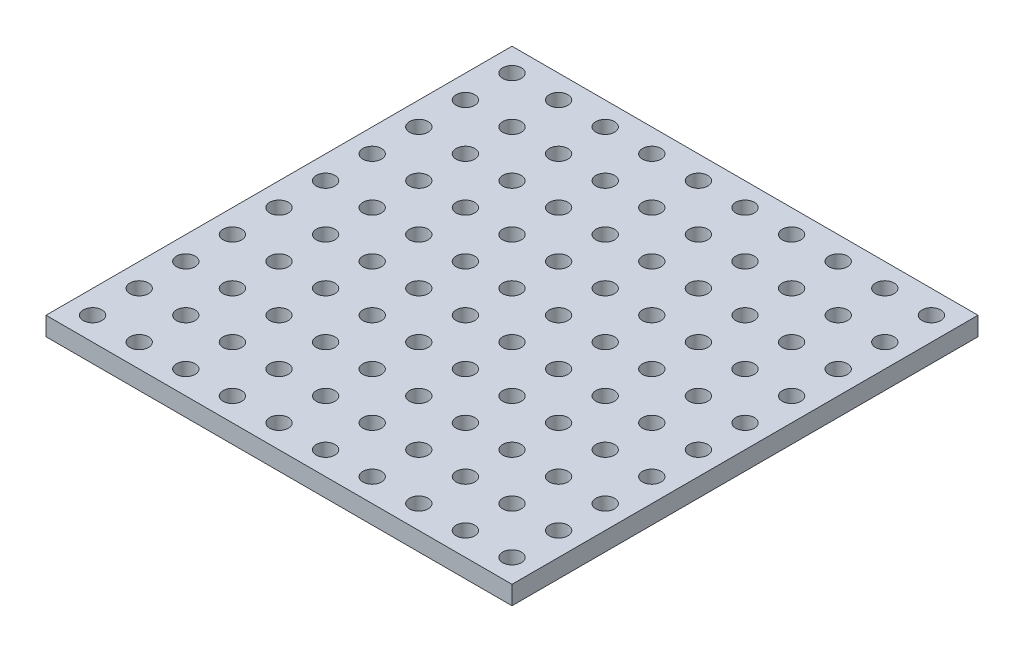
from build123d import *

# Parameters (mm, degrees)
ESBO_O1_W                = 500
ESBO_O1_H                = 500
RESSALTO_EXTRUS_O1_DEPTH = 20
ESBO_O2_R                = 10
CORTE_EXTRUS_O1_DEPTH    = 21


with BuildPart() as part:
    # Esboço1 → Ressalto-extrusão1 (new body)
    with BuildSketch(Plane(origin=(0, 0, 0), x_dir=(1, 0, 0), z_dir=(0, 1, 0))):
        Rectangle(ESBO_O1_W, ESBO_O1_H)
    extrude(amount=RESSALTO_EXTRUS_O1_DEPTH)

    # Esboço2 → Corte-extrusão1 (cut, through all)
    with BuildSketch(Plane(origin=(0, 20, 0), x_dir=(1, 0, 0), z_dir=(0, 1, 0))):
        with Locations((-225, 225)):
            Circle(ESBO_O2_R)
        with Locations((-175, 225)):
            Circle(ESBO_O2_R)
        with Locations((-125, 225)):
            Circle(ESBO_O2_R)
        with Locations((-75, 225)):
            Circle(ESBO_O2_R)
        with Locations((-25, 225)):
            Circle(ESBO_O2_R)
        with Locations((25, 225)):
            Circle(ESBO_O2_R)
        with Locations((75, 225)):
            Circle(ESBO_O2_R)
        with Locations((125, 225)):
            Circle(ESBO_O2_R)
        with Locations((175, 225)):
            Circle(ESBO_O2_R)
        with Locations((225, 225)):
            Circle(ESBO_O2_R)
        with Locations((-175, 175)):
            Circle(ESBO_O2_R)
        with Locations((-125, 175)):
            Circle(ESBO_O2_R)
        with Locations((-75, 175)):
            Circle(ESBO_O2_R)
        with Locations((-25, 175)):
            Circle(ESBO_O2_R)
        with Locations((25, 175)):
            Circle(ESBO_O2_R)
        with Locations((75, 175)):
            Circle(ESBO_O2_R)
        with Locations((125, 175)):
            Circle(ESBO_O2_R)
        with Locations((175, 175)):
            Circle(ESBO_O2_R)
        with Locations((225, 175)):
            Circle(ESBO_O2_R)
        with Locations((-175, 125)):
            Circle(ESBO_O2_R)
        with Locations((-125, 125)):
            Circle(ESBO_O2_R)
        with Locations((-75, 125)):
            Circle(ESBO_O2_R)
        with Locations((-25, 125)):
            Circle(ESBO_O2_R)
        with Locations((25, 125)):
            Circle(ESBO_O2_R)
        with Locations((75, 125)):
            Circle(ESBO_O2_R)
        with Locations((125, 125)):
            Circle(ESBO_O2_R)
        with Locations((175, 125)):
            Circle(ESBO_O2_R)
        with Locations((225, 125)):
            Circle(ESBO_O2_R)
        with Locations((-175, 75)):
            Circle(ESBO_O2_R)
        with Locations((-125, 75)):
            Circle(ESBO_O2_R)
        with Locations((-75, 75)):
            Circle(ESBO_O2_R)
        with Locations((-25, 75)):
            Circle(ESBO_O2_R)
        with Locations((25, 75)):
            Circle(ESBO_O2_R)
        with Locations((75, 75)):
            Circle(ESBO_O2_R)
        with Locations((125, 75)):
            Circle(ESBO_O2_R)
        with Locations((175, 75)):
            Circle(ESBO_O2_R)
        with Locations((225, 75)):
            Circle(ESBO_O2_R)
        with Locations((-175, 25)):
            Circle(ESBO_O2_R)
        with Locations((-125, 25)):
            Circle(ESBO_O2_R)
        with Locations((-75, 25)):
            Circle(ESBO_O2_R)
        with Locations((-25, 25)):
            Circle(ESBO_O2_R)
        with Locations((25, 25)):
            Circle(ESBO_O2_R)
        with Locations((75, 25)):
            Circle(ESBO_O2_R)
        with Locations((125, 25)):
            Circle(ESBO_O2_R)
        with Locations((175, 25)):
            Circle(ESBO_O2_R)
        with Locations((225, 25)):
            Circle(ESBO_O2_R)
        with Locations((-175, -25)):
            Circle(ESBO_O2_R)
        with Locations((-125, -25)):
            Circle(ESBO_O2_R)
        with Locations((-75, -25)):
            Circle(ESBO_O2_R)
        with Locations((-25, -25)):
            Circle(ESBO_O2_R)
        with Locations((25, -25)):
            Circle(ESBO_O2_R)
        with Locations((75, -25)):
            Circle(ESBO_O2_R)
        with Locations((125, -25)):
            Circle(ESBO_O2_R)
        with Locations((175, -25)):
            Circle(ESBO_O2_R)
        with Locations((225, -25)):
            Circle(ESBO_O2_R)
        with Locations((-175, -75)):
            Circle(ESBO_O2_R)
        with Locations((-125, -75)):
            Circle(ESBO_O2_R)
        with Locations((-75, -75)):
            Circle(ESBO_O2_R)
        with Locations((-25, -75)):
            Circle(ESBO_O2_R)
        with Locations((25, -75)):
            Circle(ESBO_O2_R)
        with Locations((75, -75)):
            Circle(ESBO_O2_R)
        with Locations((125, -75)):
            Circle(ESBO_O2_R)
        with Locations((175, -75)):
            Circle(ESBO_O2_R)
        with Locations((225, -75)):
            Circle(ESBO_O2_R)
        with Locations((-175, -125)):
            Circle(ESBO_O2_R)
        with Locations((-125, -125)):
            Circle(ESBO_O2_R)
        with Locations((-75, -125)):
            Circle(ESBO_O2_R)
        with Locations((-25, -125)):
            Circle(ESBO_O2_R)
        with Locations((25, -125)):
            Circle(ESBO_O2_R)
        with Locations((75, -125)):
            Circle(ESBO_O2_R)
        with Locations((125, -125)):
            Circle(ESBO_O2_R)
        with Locations((175, -125)):
            Circle(ESBO_O2_R)
        with Locations((225, -125)):
            Circle(ESBO_O2_R)
        with Locations((-175, -175)):
            Circle(ESBO_O2_R)
        with Locations((-125, -175)):
            Circle(ESBO_O2_R)
        with Locations((-75, -175)):
            Circle(ESBO_O2_R)
        with Locations((-25, -175)):
            Circle(ESBO_O2_R)
        with Locations((25, -175)):
            Circle(ESBO_O2_R)
        with Locations((75, -175)):
            Circle(ESBO_O2_R)
        with Locations((125, -175)):
            Circle(ESBO_O2_R)
        with Locations((175, -175)):
            Circle(ESBO_O2_R)
        with Locations((225, -175)):
            Circle(ESBO_O2_R)
        with Locations((-175, -225)):
            Circle(ESBO_O2_R)
        with Locations((-125, -225)):
            Circle(ESBO_O2_R)
        with Locations((-75, -225)):
            Circle(ESBO_O2_R)
        with Locations((-25, -225)):
            Circle(ESBO_O2_R)
        with Locations((25, -225)):
            Circle(ESBO_O2_R)
        with Locations((75, -225)):
            Circle(ESBO_O2_R)
        with Locations((125, -225)):
            Circle(ESBO_O2_R)
        with Locations((175, -225)):
            Circle(ESBO_O2_R)
        with Locations((225, -225)):
            Circle(ESBO_O2_R)
        with Locations((-225, 175)):
            Circle(ESBO_O2_R)
        with Locations((-225, 125)):
            Circle(ESBO_O2_R)
        with Locations((-225, 75)):
            Circle(ESBO_O2_R)
        with Locations((-225, 25)):
            Circle(ESBO_O2_R)
        with Locations((-225, -25)):
            Circle(ESBO_O2_R)
        with Locations((-225, -75)):
            Circle(ESBO_O2_R)
        with Locations((-225, -125)):
            Circle(ESBO_O2_R)
        with Locations((-225, -175)):
            Circle(ESBO_O2_R)
        with Locations((-225, -225)):
            Circle(ESBO_O2_R)
    extrude(amount=-CORTE_EXTRUS_O1_DEPTH, mode=Mode.SUBTRACT)


solid = part.part
